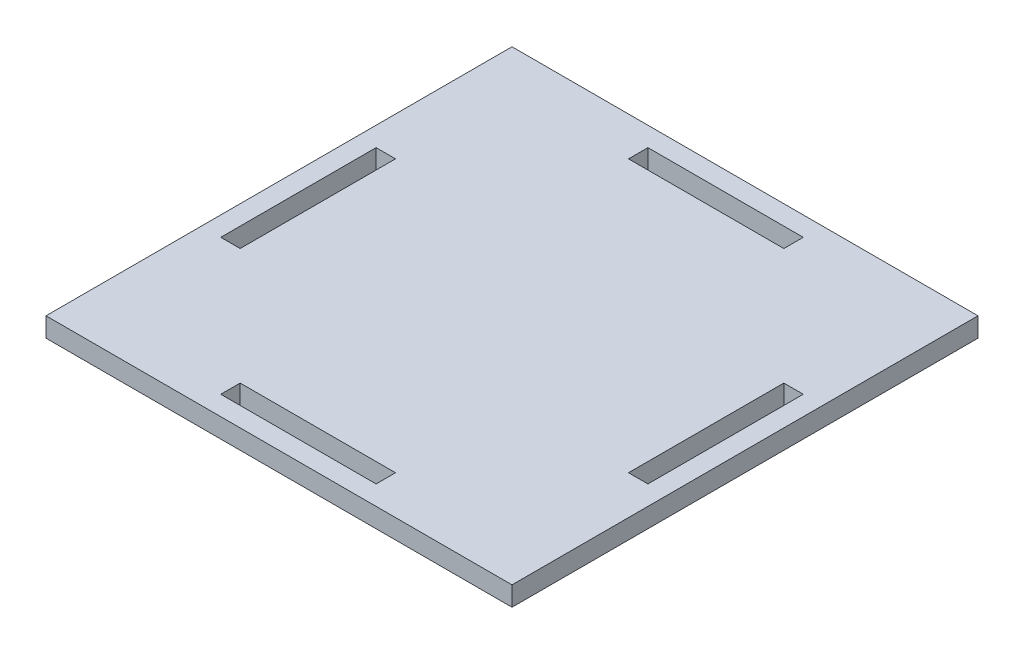
from build123d import *

# Parameters (mm, degrees)
SKETCH1_W               = 152.4
SKETCH1_H               = 152.4
BOSS_EXTRUDE1_DEPTH     = 6.35
SKETCH2_W               = 6.35
SKETCH2_H               = 50.8
SKETCH2_W_2             = 50.8
SKETCH2_H_2             = 6.35
CUT_EXTRUDE1_DEPTH      = 6.35
CUT_EXTRUDE1_DEPTH_BACK = 16.51


with BuildPart() as part:
    # Sketch1 → Boss-Extrude1 (new body)
    with BuildSketch(Plane(origin=(0, 0, 0), x_dir=(1, 0, 0), z_dir=(0, 1, 0))):
        with Locations((76.2, 76.2)):
            Rectangle(SKETCH1_W, SKETCH1_H)
    extrude(amount=BOSS_EXTRUDE1_DEPTH)

    # Sketch2 → Cut-Extrude1 (cut, two sides)
    with BuildSketch(Plane(origin=(0, 6.35, 0), x_dir=(1, 0, 0), z_dir=(0, 1, 0))) as cut_extrude1_sk:
        with Locations((9.525, 76.2)):
            Rectangle(SKETCH2_W, SKETCH2_H)
        with Locations((142.875, 76.2)):
            Rectangle(SKETCH2_W, SKETCH2_H)
        with Locations((76.2, 9.525)):
            Rectangle(SKETCH2_W_2, SKETCH2_H_2)
        with Locations((76.2, 142.875)):
            Rectangle(SKETCH2_W_2, SKETCH2_H_2)
    extrude(amount=CUT_EXTRUDE1_DEPTH, mode=Mode.SUBTRACT)
    extrude(cut_extrude1_sk.sketch, amount=-CUT_EXTRUDE1_DEPTH_BACK, mode=Mode.SUBTRACT)


solid = part.part
